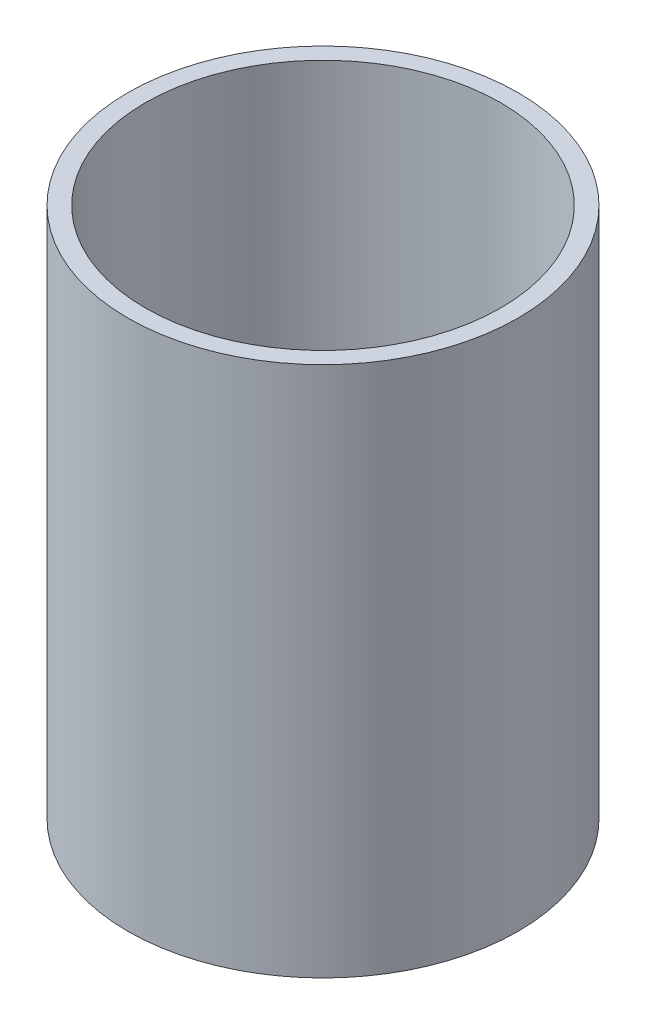
from build123d import *

# Parameters (mm, degrees)
SKETCH_1_W = 2.5
SKETCH_1_H = 76.2


with BuildPart() as part:
    # 草图1 → 旋转1 (revolve)
    with BuildSketch(Plane.XY, mode=Mode.PRIVATE) as revolve_1_sk:
        with Locations((26.75, 38.1)):
            Rectangle(SKETCH_1_W, SKETCH_1_H)
    revolve(revolve_1_sk.sketch.rotate(Axis((0, 161.376166943, 0), (0, -1, 0)), 90), axis=Axis((0, 161.376166943, 0), (0, -1, 0)))  # turned: the seam where the file's is


solid = part.part
